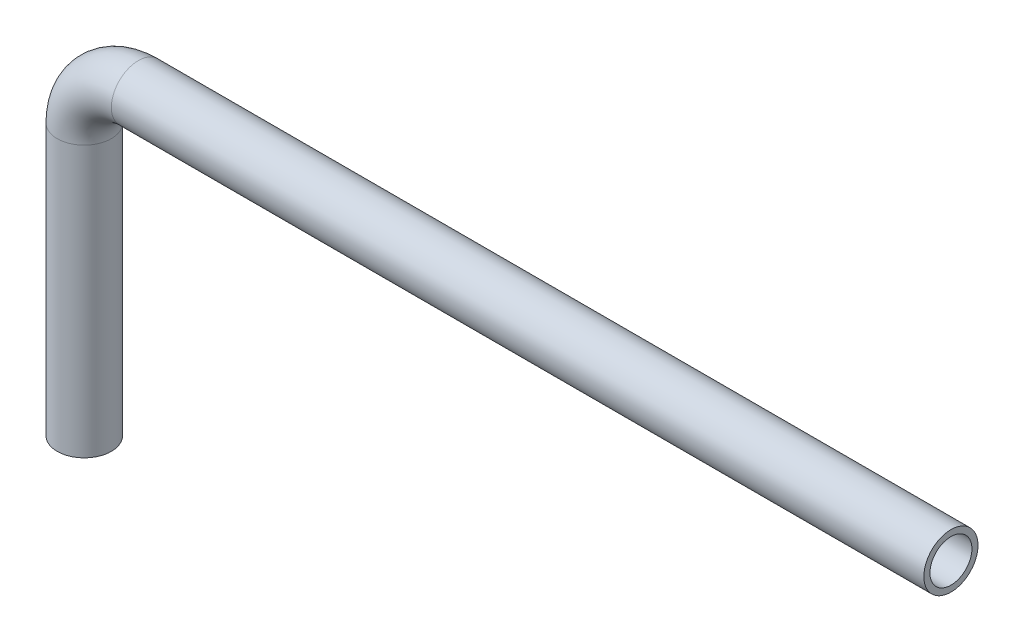
from build123d import *

# Parameters (mm, degrees)
SKETCH1_R   = 1.5875
SKETCH1_R_2 = 1.2319


with BuildPart() as part:
    # Sweep1: sweep along a path in Sketch2
    with BuildLine(Plane.XY) as sweep1_path:
        Line((0, 0), (0, 15.875))
        ThreePointArc((0, 15.875), (0.92993597, 18.12006403), (3.175, 19.05))
        Line((3.175, 19.05), (50.8, 19.05))
    # Sketch1 → Sweep1 (sweep)
    with BuildSketch(Plane(origin=(0, 0, 0), x_dir=(1, 0, 0), z_dir=(0, 1, 0))):
        Circle(SKETCH1_R)
        Circle(SKETCH1_R_2, mode=Mode.SUBTRACT)
    sweep(path=sweep1_path.line)


solid = part.part
